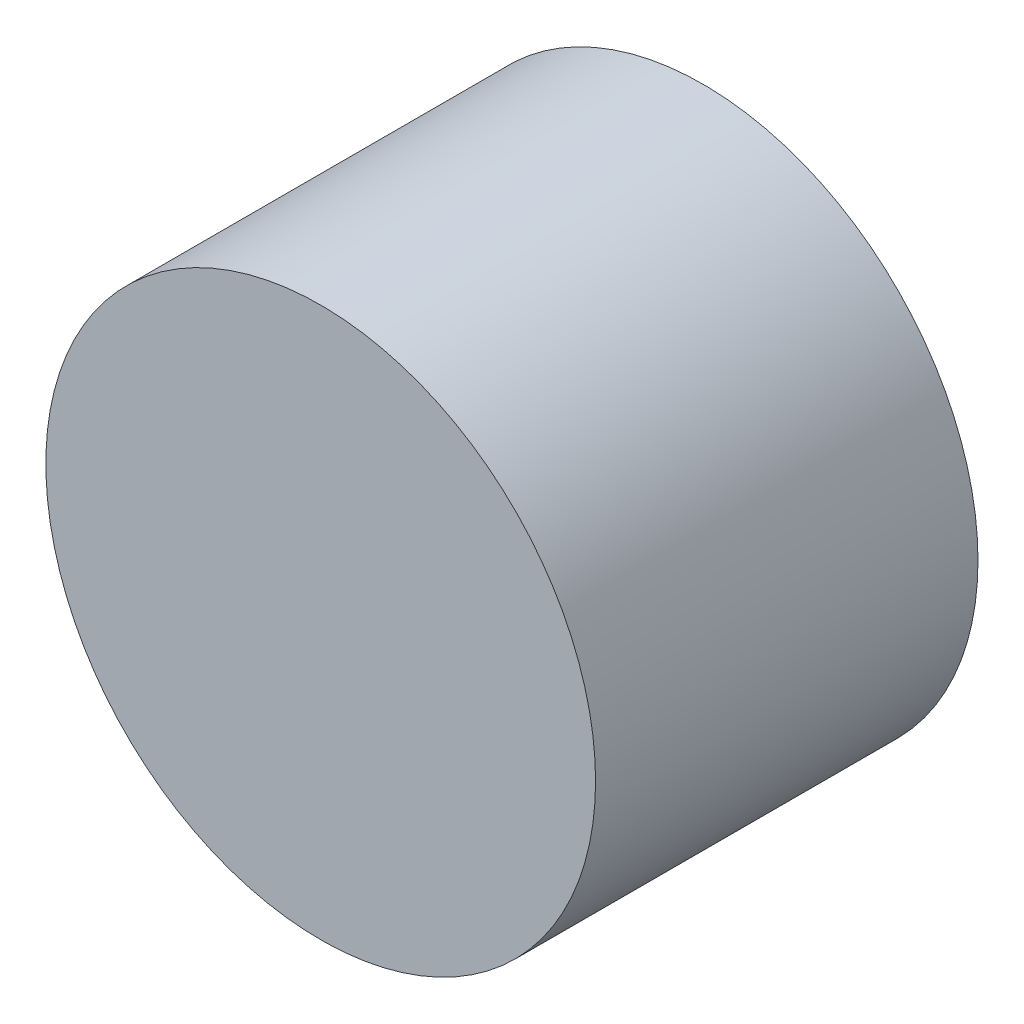
from build123d import *

# Parameters (mm, degrees)
SKETCH1_R           = 18.25625
BOSS_EXTRUDE1_DEPTH = 25.4


with BuildPart() as part:
    # Sketch1 → Boss-Extrude1 (new body)
    with BuildSketch(Plane.XY):
        Circle(SKETCH1_R)
    extrude(amount=BOSS_EXTRUDE1_DEPTH)


solid = part.part
